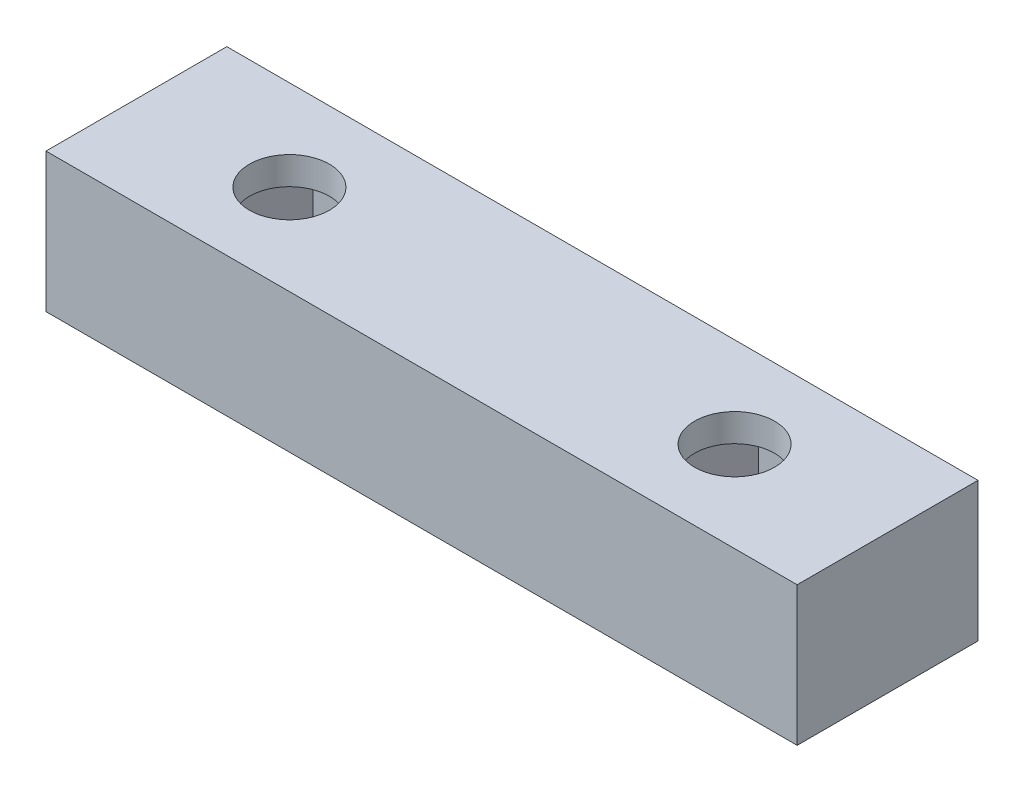
from build123d import *

# Parameters (mm, degrees)
CROQUIS1_W              = 54
CROQUIS1_H              = 13
SALIENTE_EXTRUIR1_DEPTH = 10
CORTAR_EXTRUIR1_DEPTH   = 8
CROQUIS1_4_R            = 2.875
CORTAR_EXTRUIR2_DEPTH   = 30.516944286


with BuildPart() as part:
    # Croquis1 → Saliente-Extruir1 (new body)
    with BuildSketch(Plane(origin=(0, 0, 0), x_dir=(1, 0, 0), z_dir=(0, 1, 0))):
        Rectangle(CROQUIS1_W, CROQUIS1_H)
    extrude(amount=SALIENTE_EXTRUIR1_DEPTH)

    # Croquis1_3 → Cortar-Extruir1 (cut)
    with BuildSketch(Plane(origin=(0, 0, 0), x_dir=(1, 0, 0), z_dir=(0, 1, 0))):
        Polygon((-18.33826859, -4.05), (-13.66173141, -4.05), (-11.32346282, 0), (-13.66173141, 4.05), (-18.33826859, 4.05), (-20.67653718, 0), align=None)
        Polygon((20.67653718, 0), (18.33826859, 4.05), (13.66173141, 4.05), (11.32346282, 0), (13.66173141, -4.05), (18.33826859, -4.05), align=None)
    extrude(amount=CORTAR_EXTRUIR1_DEPTH, mode=Mode.SUBTRACT)

    # Croquis1_4 → Cortar-Extruir2 (cut, through all)
    with BuildSketch(Plane(origin=(0, 0, 0), x_dir=(1, 0, 0), z_dir=(0, 1, 0))):
        with Locations((-16, 0)):
            Circle(CROQUIS1_4_R)
        with Locations((16, 0)):
            Circle(CROQUIS1_4_R)
    extrude(amount=CORTAR_EXTRUIR2_DEPTH, mode=Mode.SUBTRACT)


solid = part.part
